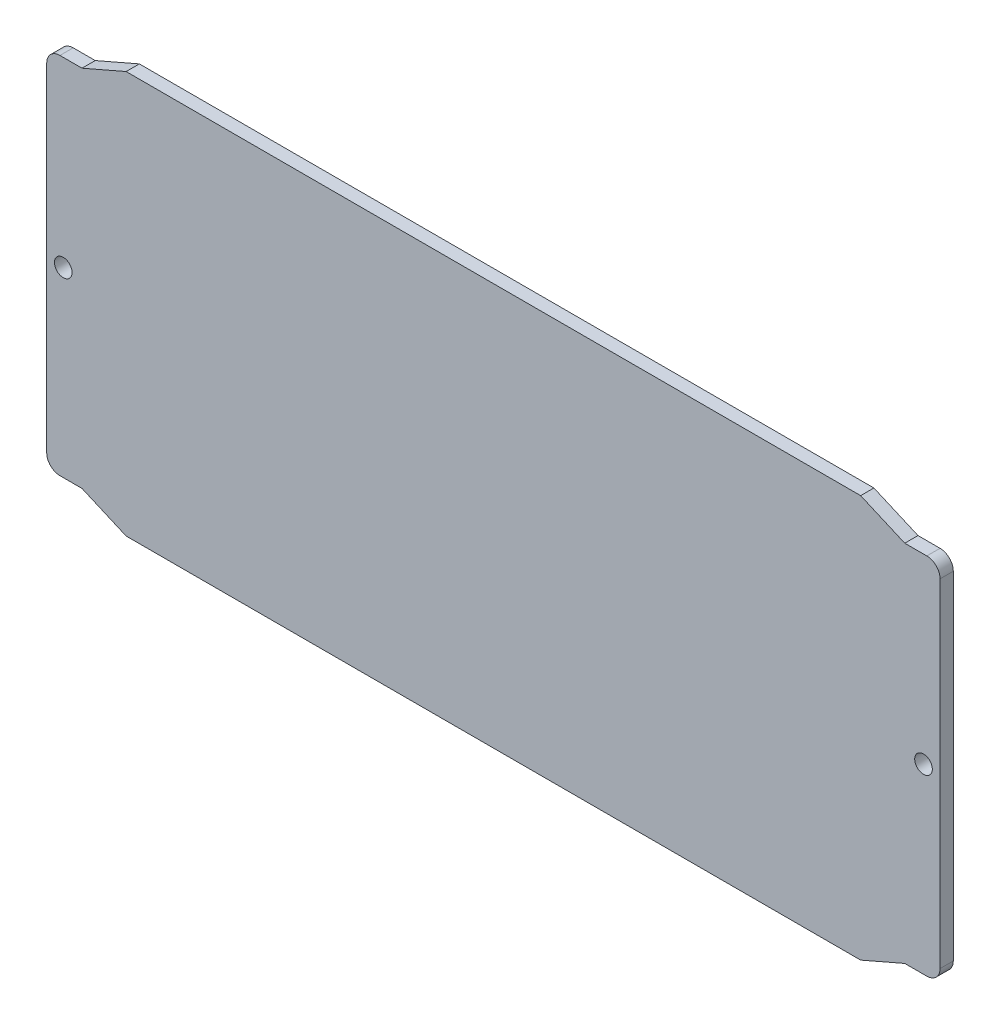
from build123d import *

# Parameters (mm, degrees)
BOSS_EXTRUDE1_DEPTH   = 3
F_4_0MM_DOWEL_HOLE1_D = 4


with BuildPart() as part:
    # Sketch1 → Boss-Extrude1 (new body)
    with BuildSketch(Plane.XY):
        with BuildLine():
            Line((0, 7.34), (0, 83.84))
            ThreePointArc((0, 83.84), (0.878679656, 85.961320344), (3, 86.84))
            Line((3, 86.84), (8, 86.84))
            Line((8, 86.84), (18, 91.18))
            Line((18, 91.18), (184.5, 91.18))
            Line((184.5, 91.18), (194.5, 86.84))
            Line((194.5, 86.84), (199.5, 86.84))
            ThreePointArc((199.5, 86.84), (201.621320344, 85.961320344), (202.5, 83.84))
            Line((202.5, 83.84), (202.5, 7.34))
            ThreePointArc((202.5, 7.34), (201.621320344, 5.218679656), (199.5, 4.34))
            Line((199.5, 4.34), (194.5, 4.34))
            Line((194.5, 4.34), (184.5, 0))
            Line((184.5, 0), (18, 0))
            Line((18, 0), (8, 4.34))
            Line((8, 4.34), (3, 4.34))
            ThreePointArc((3, 4.34), (0.878679656, 5.218679656), (0, 7.34))
        make_face()
    extrude(amount=BOSS_EXTRUDE1_DEPTH)

    # Ø4.0mm Dowel Hole1 (through all)
    with Locations(Plane.XY.offset(3)):
        with Locations((3.75, 45.59), (198.75, 45.59)):
            Hole(F_4_0MM_DOWEL_HOLE1_D / 2)


solid = part.part
